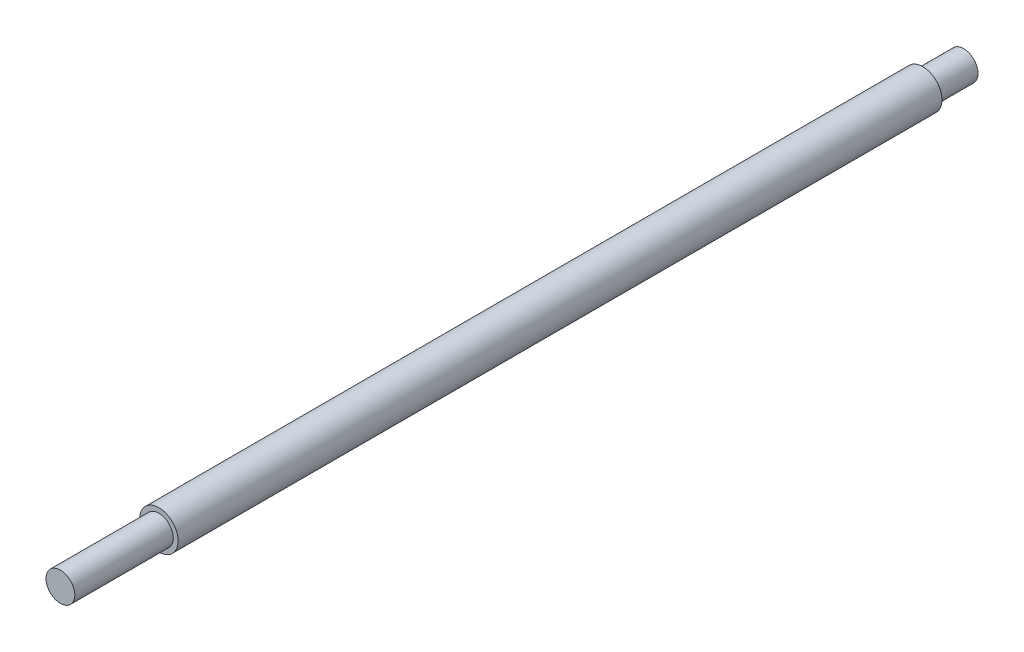
from build123d import *

# Parameters (mm, degrees)
SKETCH1_R          = 8
EXTRUDE1_DEPTH     = 366
SKETCH3_R          = 8
SKETCH3_R_2        = 6
CUT_EXTRUDE1_DEPTH = 34
SKETCH4_R          = 8
SKETCH4_R_2        = 6
CUT_EXTRUDE2_DEPTH = 20
SKETCH5_R          = 6
EXTRUDE2_DEPTH     = 10
SKETCH7_R          = 8
SKETCH7_R_2        = 6
EXTRUDE3_DEPTH     = 3
SKETCH8_R          = 8
SKETCH8_R_2        = 6
EXTRUDE4_DEPTH     = 3


with BuildPart() as part:
    # Sketch1 → Extrude1 (new body)
    with BuildSketch(Plane.XY):
        Circle(SKETCH1_R)
    extrude(amount=EXTRUDE1_DEPTH)

    # Sketch3 → Cut-Extrude1 (cut)
    with BuildSketch(Plane.XY.offset(366)):
        Circle(SKETCH3_R)
        Circle(SKETCH3_R_2, mode=Mode.SUBTRACT)
    extrude(amount=-CUT_EXTRUDE1_DEPTH, mode=Mode.SUBTRACT)

    # Sketch4 → Cut-Extrude2 (cut)
    with BuildSketch(Plane(origin=(0, 0, 0), x_dir=(-1, 0, 0), z_dir=(0, 0, -1))):
        Circle(SKETCH4_R)
        Circle(SKETCH4_R_2, mode=Mode.SUBTRACT)
    extrude(amount=-CUT_EXTRUDE2_DEPTH, mode=Mode.SUBTRACT)

    # Sketch5 → Extrude2 (add)
    with BuildSketch(Plane.XY.offset(366)):
        Circle(SKETCH5_R)
    extrude(amount=EXTRUDE2_DEPTH)

    # Sketch7 → Extrude3 (add)
    with BuildSketch(Plane.XY.offset(332)):
        Circle(SKETCH7_R)
        Circle(SKETCH7_R_2, mode=Mode.SUBTRACT)
    extrude(amount=EXTRUDE3_DEPTH)

    # Sketch8 → Extrude4 (add)
    with BuildSketch(Plane(origin=(0, 0, 20), x_dir=(-1, 0, 0), z_dir=(0, 0, -1))):
        Circle(SKETCH8_R)
        Circle(SKETCH8_R_2, mode=Mode.SUBTRACT)
    extrude(amount=EXTRUDE4_DEPTH)


solid = part.part
